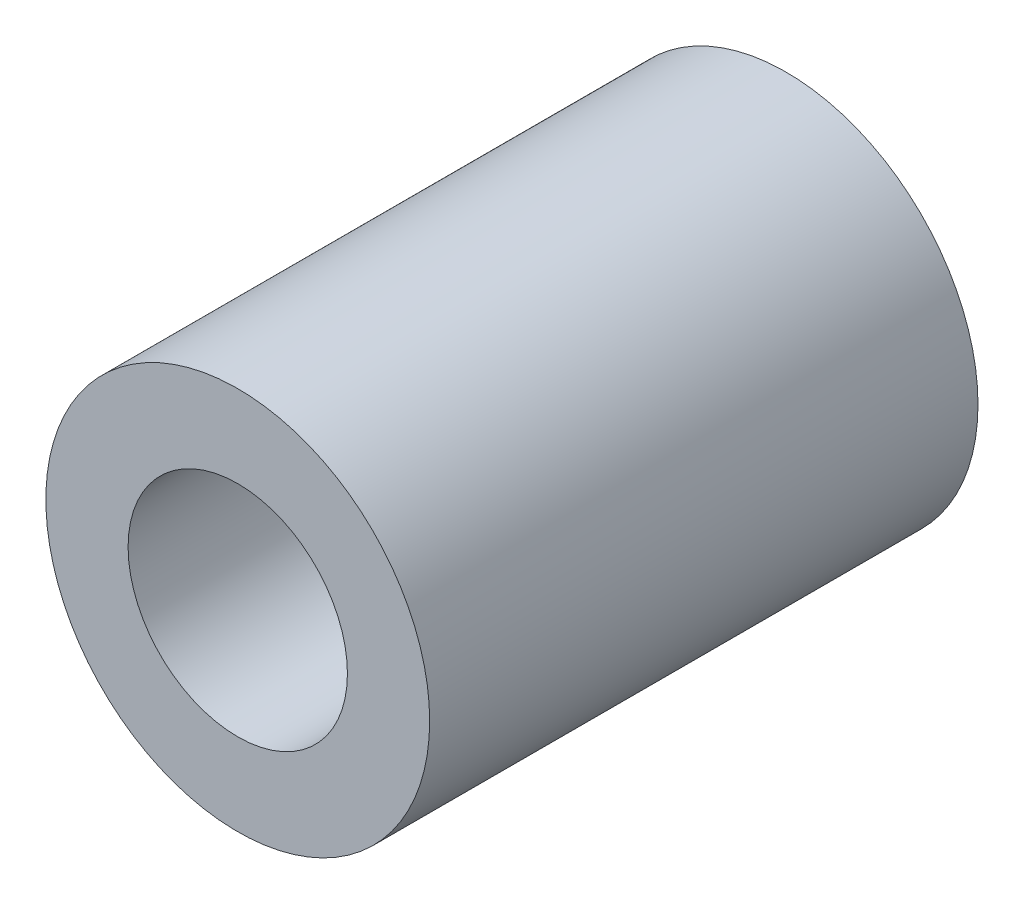
from build123d import *

# Parameters (mm, degrees)
SKETCH1_R           = 10.5
SKETCH1_R_2         = 6
BOSS_EXTRUDE1_DEPTH = 30


with BuildPart() as part:
    # Sketch1 → Boss-Extrude1 (new body)
    with BuildSketch(Plane.XY):
        Circle(SKETCH1_R)
        Circle(SKETCH1_R_2, mode=Mode.SUBTRACT)
    extrude(amount=BOSS_EXTRUDE1_DEPTH)


solid = part.part
